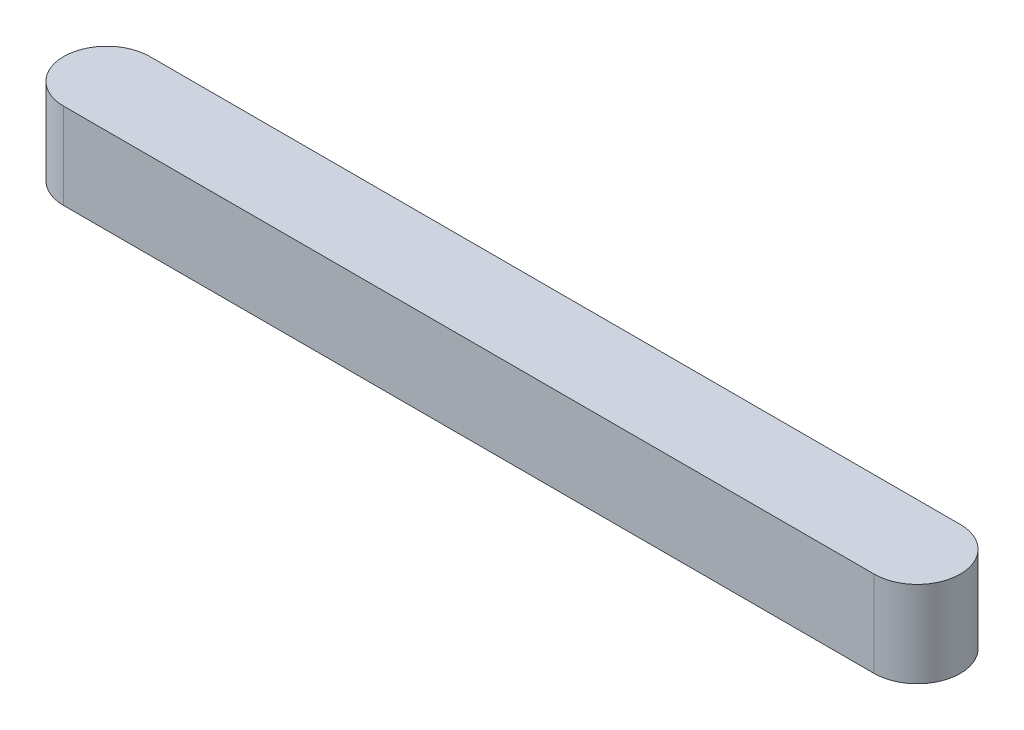
from build123d import *

# Parameters (mm, degrees)
BOSS_EXTRUDE1_DEPTH = 12


with BuildPart() as part:
    # Sketch1 → Boss-Extrude1 (new body)
    with BuildSketch(Plane(origin=(0, 0, 0), x_dir=(1, 0, 0), z_dir=(0, 1, 0))):
        with BuildLine():
            Line((-56.5, 6), (56.5, 6))
            ThreePointArc((56.5, 6), (62.5, 0), (56.5, -6))
            Line((56.5, -6), (-56.5, -6))
            ThreePointArc((-56.5, -6), (-62.5, 0), (-56.5, 6))
        make_face()
    extrude(amount=BOSS_EXTRUDE1_DEPTH)


solid = part.part
